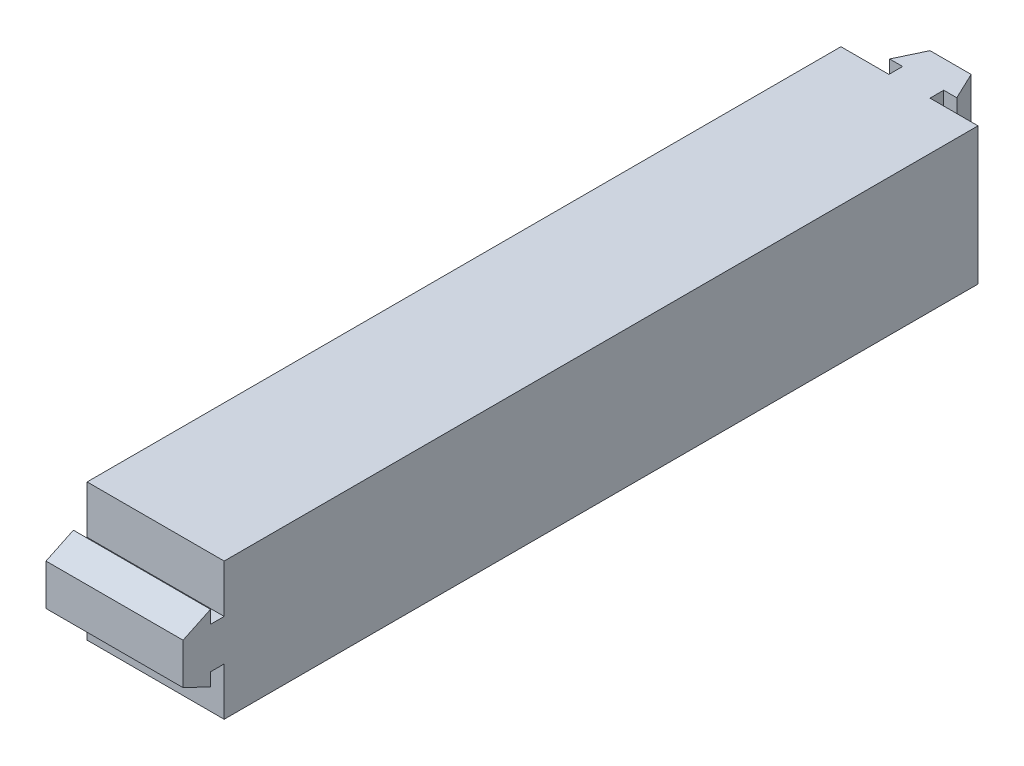
from build123d import *

# Parameters (mm, degrees)
SKETCH1_W           = 20
SKETCH1_H           = 110
BOSS_EXTRUDE1_DEPTH = 20
BOSS_EXTRUDE3_DEPTH = 20
BOSS_EXTRUDE4_DEPTH = 20


with BuildPart() as part:
    # Sketch1 → Boss-Extrude1 (new body)
    with BuildSketch(Plane(origin=(0, 0, 0), x_dir=(1, 0, 0), z_dir=(0, 1, 0))):
        with Locations((10, 55)):
            Rectangle(SKETCH1_W, SKETCH1_H)
    extrude(amount=BOSS_EXTRUDE1_DEPTH)

    # Sketch3 → Boss-Extrude3 (add)
    with BuildSketch(Plane(origin=(0, 0, 0), x_dir=(0, 0, -1), z_dir=(1, 0, 0))):
        Polygon((0, 7), (0, 13), (-2, 13), (-2, 14.9), (-6, 13), (-6, 7), (-2, 5.1), (-2, 7), align=None)
    extrude(amount=BOSS_EXTRUDE3_DEPTH)

    # Sketch5 → Boss-Extrude4 (add)
    with BuildSketch(Plane(origin=(0, 20, 0), x_dir=(1, 0, 0), z_dir=(0, 1, 0))):
        Polygon((13, 110), (7, 110), (7, 112), (5.1, 112), (7, 116), (13, 116), (14.9, 112), (13, 112), align=None)
    extrude(amount=-BOSS_EXTRUDE4_DEPTH)


solid = part.part
